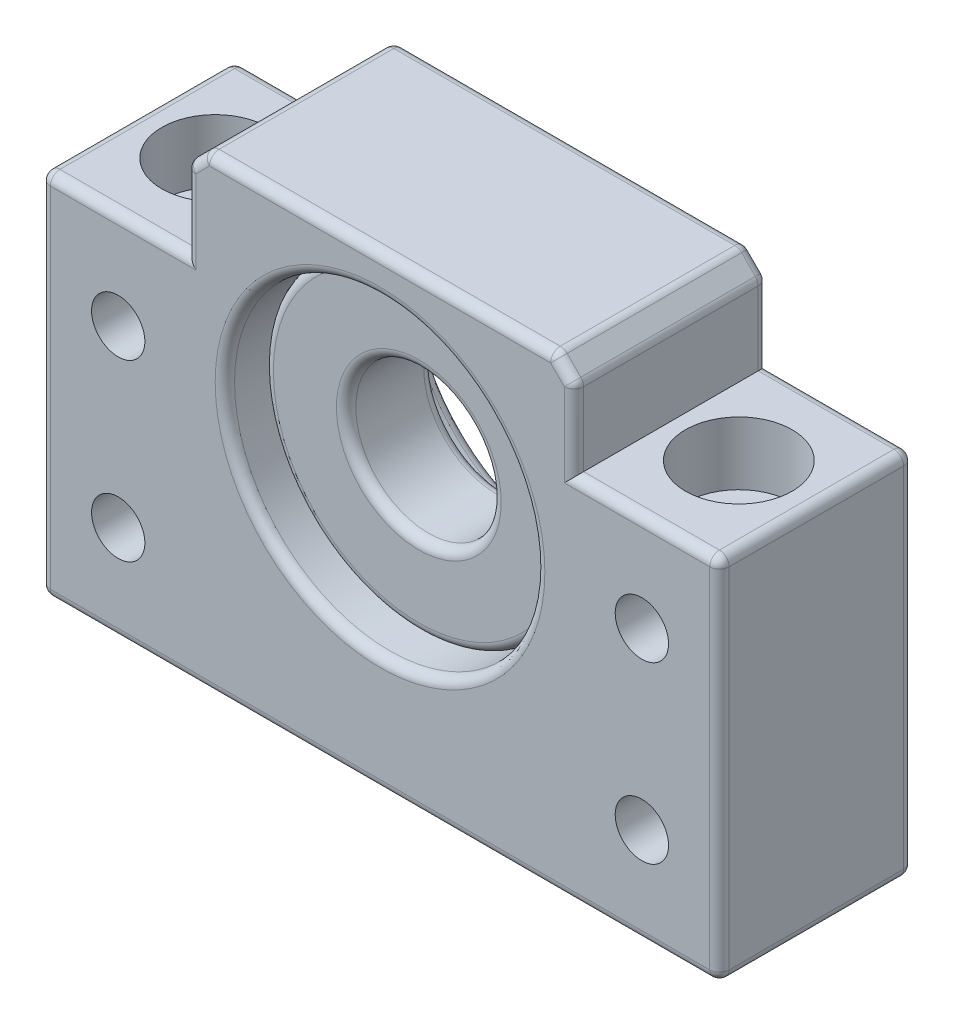
from build123d import *

# Parameters (mm, degrees)
BOSS_EXTRUDE1_DEPTH = 20
SKETCH12_R          = 3.3
CUT_EXTRUDE3_DEPTH  = 100
SKETCH13_R          = 2.75
SKETCH13_R_2        = 16
CUT_EXTRUDE4_DEPTH  = 50
SKETCH14_R          = 5.5
CUT_EXTRUDE5_DEPTH  = 6.5
BOSS_EXTRUDE3_START = 7
SKETCH16_R          = 16
SKETCH16_R_2        = 7.5
BOSS_EXTRUDE3_DEPTH = 9
CHAMFER1_SIZE       = 2
FILLET1_R           = 1
FILLET2_R           = 1


with BuildPart() as part:
    # Sketch2 → Boss-Extrude1 (new body)
    with BuildSketch(Plane.XY):
        Polygon((-35, 10), (-20, 10), (-20, 20), (20, 20), (20, 10), (35, 10), (35, -28), (-35, -28), align=None)
    extrude(amount=BOSS_EXTRUDE1_DEPTH)

    # Sketch12 → Cut-Extrude3 (cut)
    with BuildSketch(Plane(origin=(0, 10, 0), x_dir=(1, 0, 0), z_dir=(0, 1, 0))):
        with Locations((-27, -10)):
            Circle(SKETCH12_R)
        with Locations((27, -10)):
            Circle(SKETCH12_R)
    extrude(amount=-CUT_EXTRUDE3_DEPTH, mode=Mode.SUBTRACT)

    # Sketch13 → Cut-Extrude4 (cut)
    with BuildSketch(Plane.XY):
        with Locations((-27, 0)):
            Circle(SKETCH13_R)
        with Locations((-27, -18)):
            Circle(SKETCH13_R)
        with Locations((27, -18)):
            Circle(SKETCH13_R)
        with Locations((27, 0)):
            Circle(SKETCH13_R)
        Circle(SKETCH13_R_2)
    extrude(amount=CUT_EXTRUDE4_DEPTH, mode=Mode.SUBTRACT)

    # Sketch14 → Cut-Extrude5 (cut)
    with BuildSketch(Plane(origin=(0, 10, 0), x_dir=(1, 0, 0), z_dir=(0, 1, 0))):
        with Locations((-27, -10)):
            Circle(SKETCH14_R)
        with Locations((27, -10)):
            Circle(SKETCH14_R)
    extrude(amount=-CUT_EXTRUDE5_DEPTH, mode=Mode.SUBTRACT)

    # Chamfer1
    chamfer1_edges = [part.edges().sort_by_distance(p)[0] for p in [
        (-20, 20, 10),
        (20, 20, 10),
    ]]
    chamfer(chamfer1_edges, length=CHAMFER1_SIZE)

    # Fillet1
    fillet1_edges = [part.edges().sort_by_distance(p)[0] for p in [
        (27.5, 10, 0),
        (35, -9, 0),
        (0, -28, 0),
        (-35, -9, 0),
        (35, -9, 20),
        (-35, 10, 10),
        (35, 10, 10),
        (35, -28, 10),
        (-35, -28, 10),
        (27.5, 10, 20),
        (20, 14, 20),
        (-27.5, 10, 20),
        (-35, -9, 20),
        (-16, 0, 20),
        (-16, 0, 0),
        (-27.5, 10, 0),
        (0, -28, 20),
        (-20, 14, 0),
        (-20, 14, 20),
        (-20, 18, 10),
        (0, 20, 0),
        (19, 19, 0),
        (-19, 19, 0),
        (0, 20, 20),
        (18, 20, 10),
        (-18, 20, 10),
        (19, 19, 20),
        (-19, 19, 20),
        (20, 18, 10),
        (20, 14, 0),
    ]]
    fillet(fillet1_edges, radius=FILLET1_R)


with BuildPart() as body_2:
    # Sketch16 → Boss-Extrude3 (new body)
    with BuildSketch(Plane.XY.offset(BOSS_EXTRUDE3_START)):
        Circle(SKETCH16_R)
        Circle(SKETCH16_R_2, mode=Mode.SUBTRACT)
    extrude(amount=BOSS_EXTRUDE3_DEPTH)

    # Fillet2
    fillet2_edges = [body_2.edges().sort_by_distance(p)[0] for p in [
        (-16, 0, 7),
        (-16, 0, 16),
        (-7.5, 0, 7),
        (-7.5, 0, 16),
    ]]
    fillet(fillet2_edges, radius=FILLET2_R)


solid = Compound([part.part, body_2.part])
